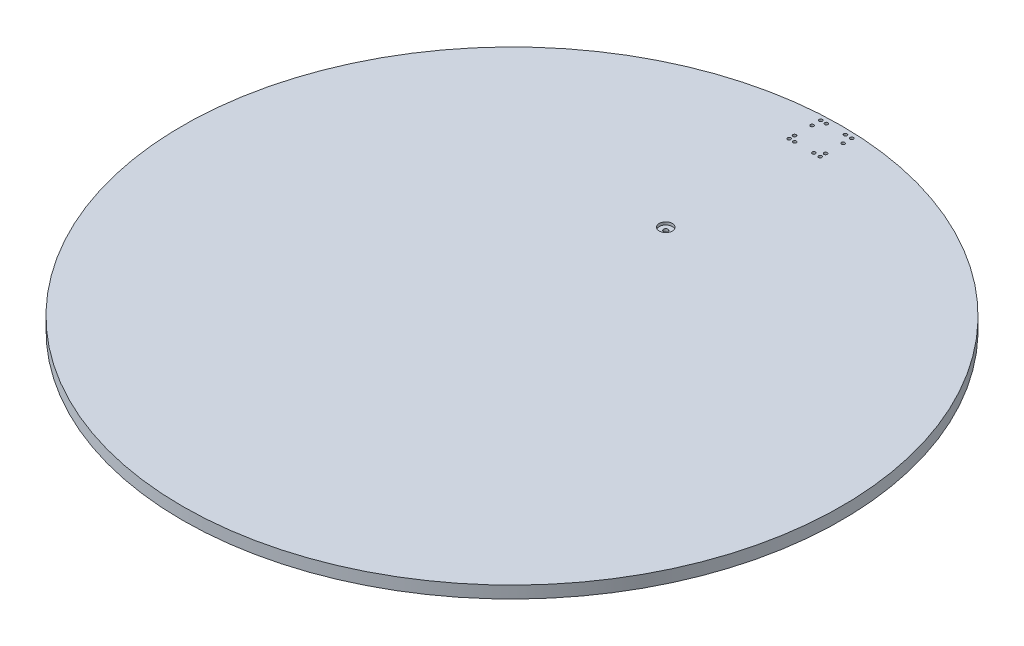
from build123d import *

# Parameters (mm, degrees)
ESQUISSE1_R             = 600
BOSS_EXTRU_1_DEPTH      = 22
ESQUISSE2_R             = 4
ENL_V_MAT_EXTRU_1_DEPTH = 23
ENL_V_MAT_EXTRU_2_DEPTH = 8
ESQUISSE4_R             = 12
ENL_V_MAT_EXTRU_3_DEPTH = 5
ESQUISSE6_R             = 3
ENL_V_MAT_EXTRU_4_DEPTH = 23


with BuildPart() as part:
    # Esquisse1 → Boss.-Extru.1 (new body)
    with BuildSketch(Plane(origin=(0, 0, 0), x_dir=(1, 0, 0), z_dir=(0, 1, 0))):
        with Locations(Location((0, 0, 0), (0, 0, 270))):  # turned: the seam where the file's is
            Circle(ESQUISSE1_R)
    extrude(amount=BOSS_EXTRU_1_DEPTH)

    # Esquisse2 → Enlèv. mat.-Extru.1 (cut, through all)
    with BuildSketch(Plane(origin=(0, 22, 0), x_dir=(1, 0, 0), z_dir=(0, 1, 0))):
        with Locations(Location((0, 280, 0), (0, 0, 270))):  # turned: the seam where the file's is
            Circle(ESQUISSE2_R)
    extrude(amount=-ENL_V_MAT_EXTRU_1_DEPTH, mode=Mode.SUBTRACT)

    # Esquisse3 → Enlèv. mat.-Extru.2 (cut)
    with BuildSketch(Plane.XZ):
        Polygon((6.5, -280), (6.5, -276.24722325), (3.25, -274.370834875), (0, -272.494446501), (-3.25, -274.370834875), (-6.5, -276.24722325), (-6.5, -280), (-6.5, -283.75277675), (-3.25, -285.629165125), (0, -287.505553499), (3.25, -285.629165125), (6.5, -283.75277675), align=None)
    extrude(amount=-ENL_V_MAT_EXTRU_2_DEPTH, mode=Mode.SUBTRACT)

    # Esquisse4 → Enlèv. mat.-Extru.3 (cut)
    with BuildSketch(Plane(origin=(0, 22, 0), x_dir=(1, 0, 0), z_dir=(0, 1, 0))):
        with Locations(Location((0, 280, 0), (0, 0, 270))):  # turned: the seam where the file's is
            Circle(ESQUISSE4_R)
    extrude(amount=-ENL_V_MAT_EXTRU_3_DEPTH, mode=Mode.SUBTRACT)

    # Esquisse6 → Enlèv. mat.-Extru.4 (cut, through all)
    with BuildSketch(Plane(origin=(0, 22, 0), x_dir=(1, 0, 0), z_dir=(0, 1, 0))):
        with Locations(Location((-27.359707791, 541.773153337, 0), (0, 0, 270))):  # turned: the seam where the file's is
            Circle(ESQUISSE6_R)
        with Locations(Location((-27.359707791, 531.883070045, 0), (0, 0, 270))):  # turned: the seam where the file's is
            Circle(ESQUISSE6_R)
        with Locations(Location((-17.338422342, 531.883070045, 0), (0, 0, 270))):  # turned: the seam where the file's is
            Circle(ESQUISSE6_R)
        with Locations(Location((-27.359707791, 589.516341352, 0), (0, 0, 270))):  # turned: the seam where the file's is
            Circle(ESQUISSE6_R)
        with Locations(Location((-27.359707791, 573.664786381, 0), (0, 0, 270))):  # turned: the seam where the file's is
            Circle(ESQUISSE6_R)
        with Locations(Location((-17.338422342, 589.516341352, 0), (0, 0, 270))):  # turned: the seam where the file's is
            Circle(ESQUISSE6_R)
        with Locations(Location((17.587577233, 589.516341352, 0), (0, 0, 270))):  # turned: the seam where the file's is
            Circle(ESQUISSE6_R)
        with Locations(Location((29.13602426, 589.516341352, 0), (0, 0, 270))):  # turned: the seam where the file's is
            Circle(ESQUISSE6_R)
        with Locations(Location((29.13602426, 573.664786381, 0), (0, 0, 270))):  # turned: the seam where the file's is
            Circle(ESQUISSE6_R)
        with Locations(Location((29.13602426, 541.773153337, 0), (0, 0, 270))):  # turned: the seam where the file's is
            Circle(ESQUISSE6_R)
        with Locations(Location((29.13602426, 531.883070045, 0), (0, 0, 270))):  # turned: the seam where the file's is
            Circle(ESQUISSE6_R)
        with Locations(Location((17.587577233, 531.883070045, 0), (0, 0, 270))):  # turned: the seam where the file's is
            Circle(ESQUISSE6_R)
    extrude(amount=-ENL_V_MAT_EXTRU_4_DEPTH, mode=Mode.SUBTRACT)


solid = part.part
